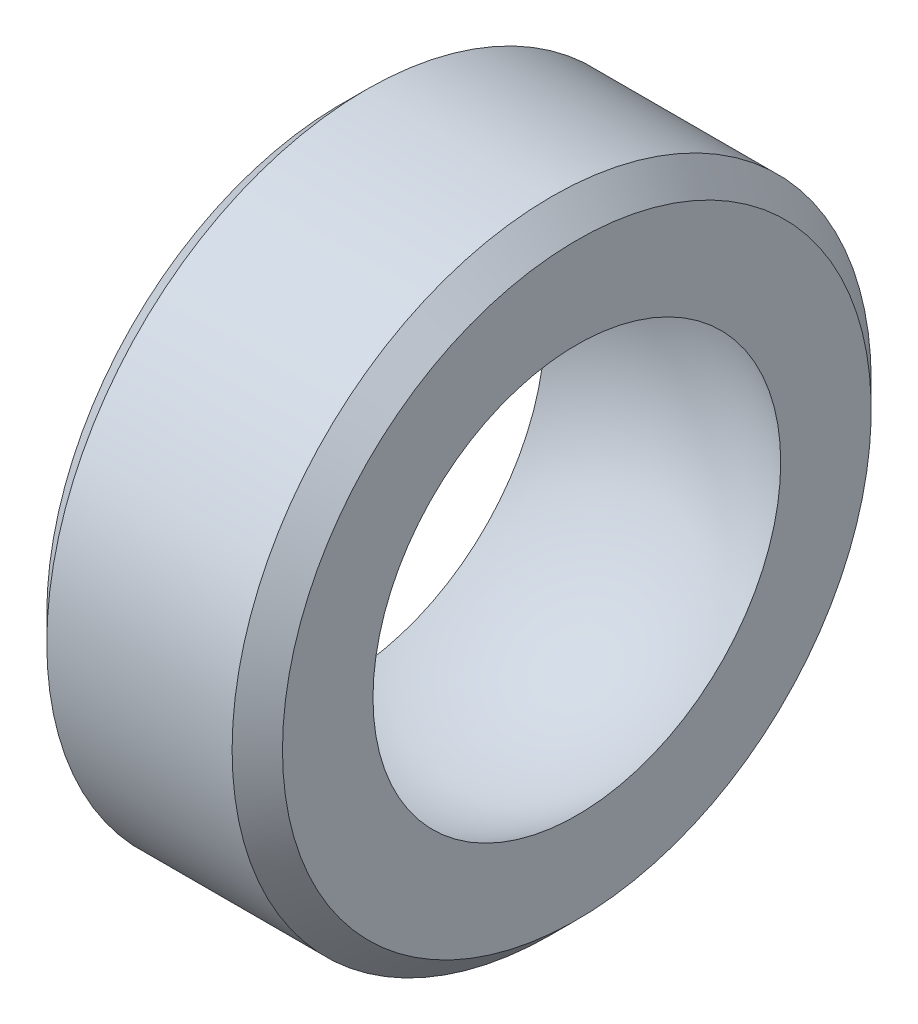
from build123d import *


with BuildPart() as part:
    # Sketch1 → Revolve1 (revolve)
    with BuildSketch(Plane.XY):
        with BuildLine():
            Line((-3.555, 6.15), (-3.555, 8.88))
            Line((-3.555, 8.88), (-2.795, 9.64))
            Line((-2.795, 9.64), (2.795, 9.64))
            Line((2.795, 9.64), (3.555, 8.88))
            Line((3.555, 8.88), (3.555, 6.15))
            ThreePointArc((3.555, 6.15), (0, 7.103557207), (-3.555, 6.15))
        make_face()
    revolve(axis=Axis((-3.555, 0, 0), (1, 0, 0)))


solid = part.part
